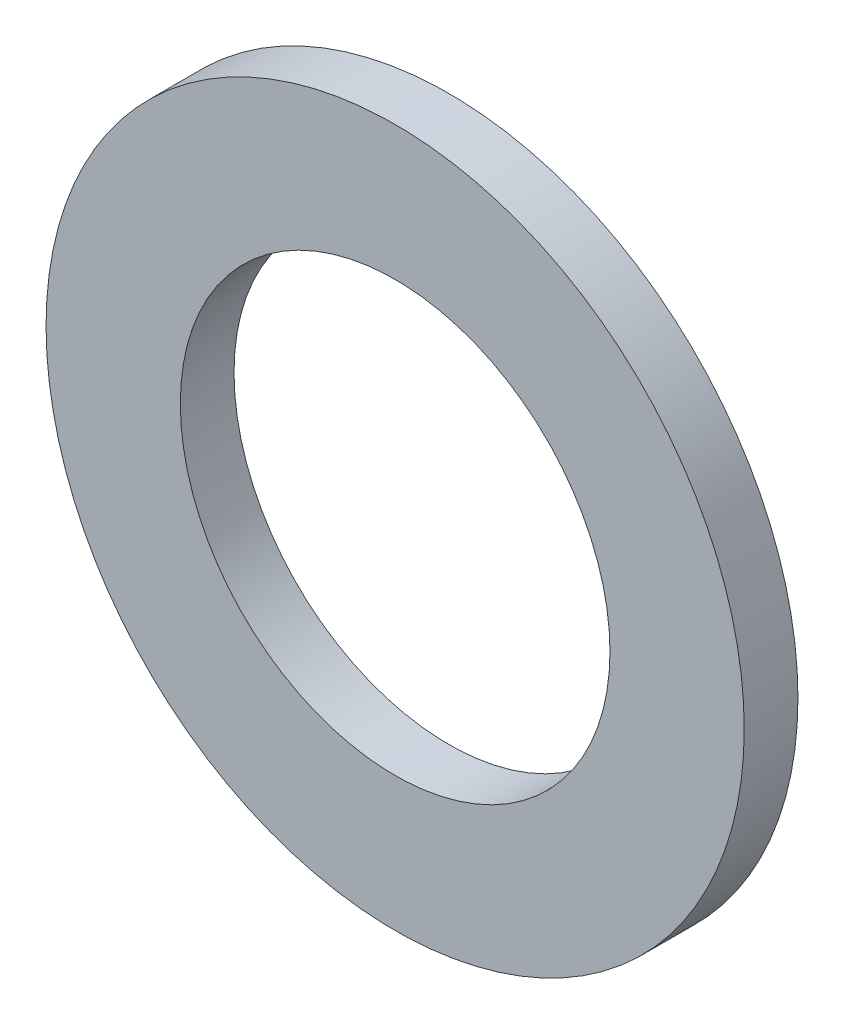
from build123d import *

# Parameters (mm, degrees)
SKETCH1_R           = 6.5
SKETCH1_R_2         = 4
BOSS_EXTRUDE1_DEPTH = 1


with BuildPart() as part:
    # Sketch1 → Boss-Extrude1 (new body)
    with BuildSketch(Plane.XY):
        Circle(SKETCH1_R)
        Circle(SKETCH1_R_2, mode=Mode.SUBTRACT)
    extrude(amount=BOSS_EXTRUDE1_DEPTH)


solid = part.part
